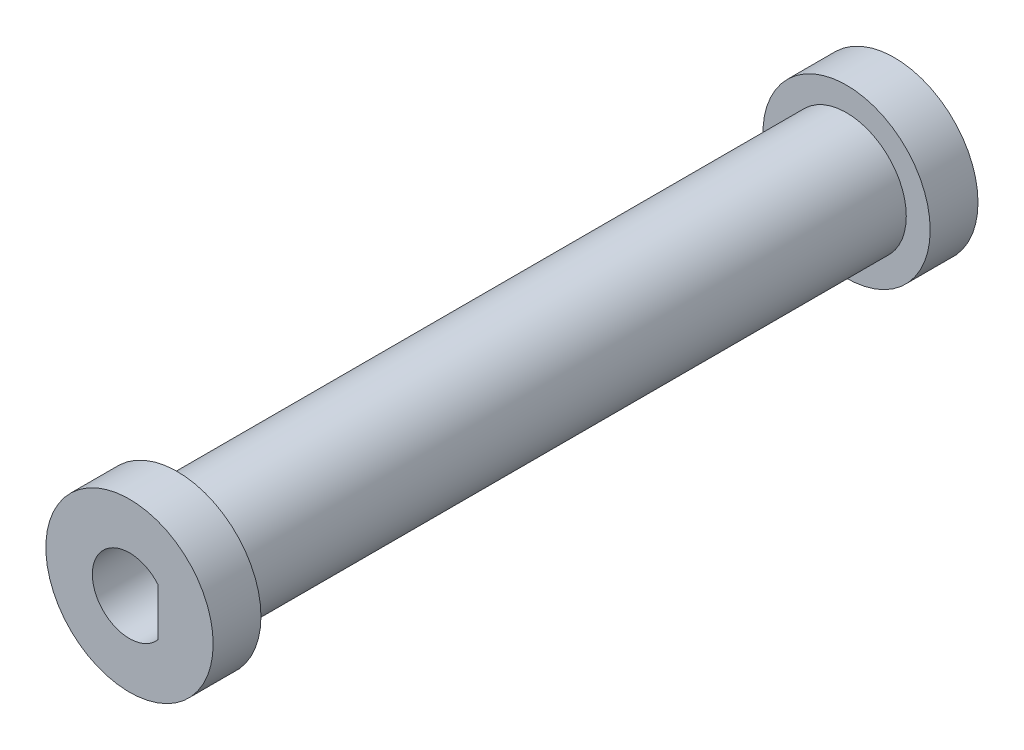
from build123d import *

# Parameters (mm, degrees)
SKETCH1_R           = 3.175
BOSS_EXTRUDE1_DEPTH = 35.56
SKETCH3_R           = 4.445
BOSS_EXTRUDE2_DEPTH = 2.54
CUT_EXTRUDE1_DEPTH  = 10.16


with BuildPart() as part:
    # Sketch1 → Boss-Extrude1 (new body)
    with BuildSketch(Plane.XY):
        Circle(SKETCH1_R)
    extrude(amount=BOSS_EXTRUDE1_DEPTH)

    # Sketch3 → Boss-Extrude2 (add)
    with BuildSketch(Plane.XY.offset(35.56)):
        Circle(SKETCH3_R)
    boss_extrude2 = extrude(amount=BOSS_EXTRUDE2_DEPTH)

    # Mirror1: Boss-Extrude2 across plane
    add(boss_extrude2.mirror(Plane.XY.offset(17.78)))

    # Sketch4 → Cut-Extrude1 (cut)
    with BuildSketch(Plane.XY.offset(38.1)):
        with BuildLine():
            Line((1.525, 0), (1.525, 1.25499004))
            ThreePointArc((1.525, 1.25499004), (-1.975, 0), (1.525, -1.25499004))
            Line((1.525, -1.25499004), (1.525, 0))
        make_face()
    extrude(amount=-CUT_EXTRUDE1_DEPTH, mode=Mode.SUBTRACT)


solid = part.part
